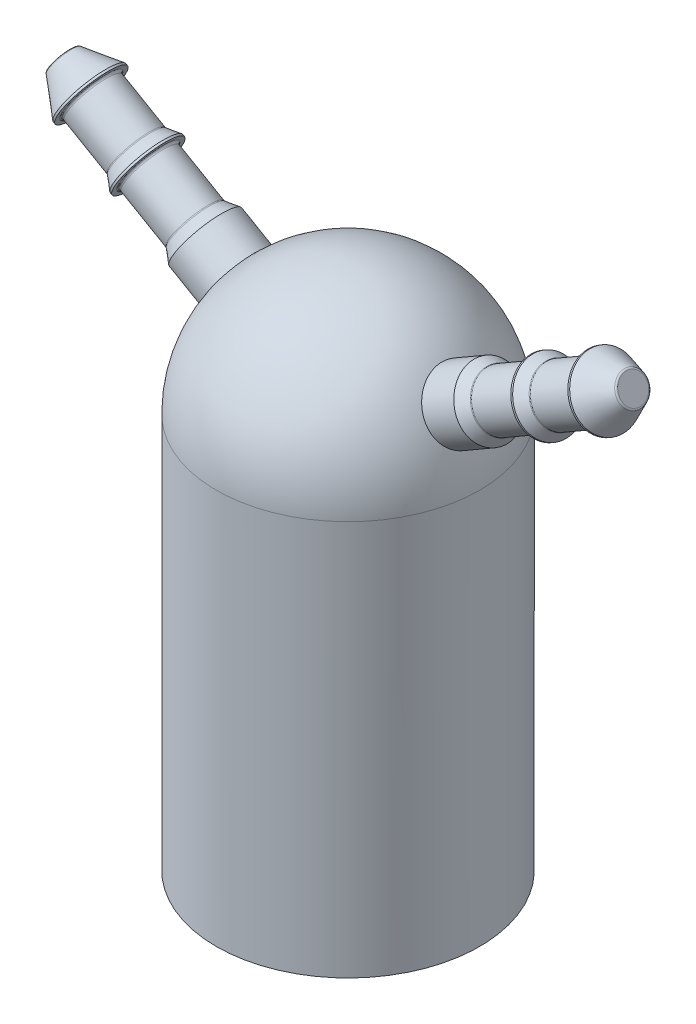
from build123d import *

# Parameters (mm, degrees)
CUT_EXTRUDE1_DEPTH   = 12.7
FILLET1_R            = 0.1016
FILLET1_OF_MIRROR1_R = 0.1016


with BuildPart() as part:
    # Sketch1 → Revolve1 (revolve)
    with BuildSketch(Plane.XY):
        with BuildLine():
            Line((0, 0), (0, 25.4))
            ThreePointArc((0, 25.4), (-4.490128061, 23.540128061), (-6.35, 19.05))
            Line((-6.35, 19.05), (-6.35, 0))
            Line((-6.35, 0), (0, 0))
        make_face()
    revolve(axis=Axis((0, 0, 0), (0, 1, 0)))

    # Sketch2 → Cut-Extrude1 (cut)
    with BuildSketch(Plane.XZ):
        with BuildLine():
            Line((2.87588847, 3.052663666), (2.491556541, 2.644707609))
            ThreePointArc((2.491556541, 2.644707609), (2.422052451, 2.612873916), (2.350030514, 2.638506769))
            ThreePointArc((2.350030514, 2.638506769), (2.10893298, 2.83491853), (1.851499358, 3.009370618))
            ThreePointArc((1.851499358, 3.009370618), (1.80624286, 3.070982727), (1.816750694, 3.146704507))
            Line((1.816750694, 3.146704507), (2.096991294, 3.632095464))
            add(Edge.make_bspline(
                [(2.133429555, 4.749876804), (2.173353678, 4.56476612), (2.196583124, 4.376018446), (2.195632116, 4.092198703), (2.189337304, 3.997490868), (2.16733456, 3.857272905), (2.157906341, 3.810840598), (2.133266211, 3.719484674), (2.11977921, 3.673567613), (2.096991294, 3.632095464)],
                knots=[0, 0, 0, 0, 0.5, 0.5, 0.75, 0.75, 0.875, 0.875, 1, 1, 1, 1], degree=3))
            ThreePointArc((2.133429555, 4.749876804), (1.920714415, 4.839804486), (1.704220965, 4.920211604))
            add(Edge.make_bspline(
                [(0.964260641, 4.081628519), (0.976112248, 4.127440828), (0.997781643, 4.170110641), (1.042491275, 4.253501826), (1.11742258, 4.374285652), (1.207964167, 4.484162484), (1.401892207, 4.691397776), (1.548227803, 4.812852233), (1.704220965, 4.920211604)],
                knots=[0, 0, 0, 0, 0.125, 0.125, 0.25, 0.5, 0.5, 1, 1, 1, 1], degree=3))
            Line((0.964260641, 4.081628519), (0.835397453, 3.536162244))
            ThreePointArc((0.835397453, 3.536162244), (0.791121992, 3.473841414), (0.71593274, 3.460029147))
            ThreePointArc((0.71593274, 3.460029147), (0.408930271, 3.509577955), (0.09876017, 3.531941083))
            ThreePointArc((0.09876017, 3.531941083), (0.028760839, 3.562670485), (0, 3.633501387))
            Line((0, 3.633501387), (0, 4.193982588))
            add(Edge.make_bspline(
                [(-0.527334211, 5.180228755), (-0.400203563, 5.039880261), (-0.285712436, 4.888034703), (-0.144626161, 4.641764092), (-0.102723711, 4.556597294), (-0.051669665, 4.424163605), (-0.036618589, 4.379237938), (-0.012279605, 4.287801322), (-0.00100116, 4.24129248), (0, 4.193982588)],
                knots=[0, 0, 0, 0, 0.5, 0.5, 0.75, 0.75, 0.875, 0.875, 1, 1, 1, 1], degree=3))
            ThreePointArc((-0.527334211, 5.180228755), (-0.756514766, 5.151750841), (-0.984207153, 5.113138723))
            add(Edge.make_bspline(
                [(-1.205740048, 4.016924306), (-1.21838241, 4.062524733), (-1.22095107, 4.110312573), (-1.223926985, 4.204886274), (-1.219426485, 4.346953788), (-1.195953586, 4.487380709), (-1.131624624, 4.763815757), (-1.065621508, 4.942166199), (-0.984207153, 5.113138723)],
                knots=[0, 0, 0, 0, 0.125, 0.125, 0.25, 0.5, 0.5, 1, 1, 1, 1], degree=3))
            Line((-1.205740048, 4.016924306), (-1.044605706, 3.480105064))
            ThreePointArc((-1.044605706, 3.480105064), (-1.051788963, 3.40399591), (-1.109998633, 3.354439509))
            ThreePointArc((-1.109998633, 3.354439509), (-1.400644974, 3.243848801), (-1.680441725, 3.108130788))
            ThreePointArc((-1.680441725, 3.108130788), (-1.756427626, 3.099743565), (-1.816750695, 3.146704507))
            Line((-1.816750695, 3.146704507), (-2.096991295, 3.632095464))
            add(Edge.make_bspline(
                [(-3.046799201, 4.222542594), (-2.866526584, 4.164562557), (-2.69145158, 4.090306009), (-2.446131977, 3.947572541), (-2.367259991, 3.894767156), (-2.256829045, 3.80560324), (-2.221331598, 3.774222009), (-2.154535111, 3.707205069), (-2.121513271, 3.672566452), (-2.096991295, 3.632095464)],
                knots=[0, 0, 0, 0, 0.5, 0.5, 0.75, 0.75, 0.875, 0.875, 1, 1, 1, 1], degree=3))
            ThreePointArc((-3.046799201, 4.222542594), (-3.231036427, 4.083289719), (-3.408917759, 3.936004451))
            add(Edge.make_bspline(
                [(-3.052663666, 2.87588847), (-3.086412486, 2.909058417), (-3.112530931, 2.949159571), (-3.162394999, 3.029574841), (-3.229531209, 3.154859167), (-3.279416543, 3.288208898), (-3.361923551, 3.559773153), (-3.393938397, 3.747230725), (-3.408917759, 3.936004451)],
                knots=[0, 0, 0, 0, 0.125, 0.125, 0.25, 0.5, 0.5, 1, 1, 1, 1], degree=3))
            Line((-3.052663666, 2.87588847), (-2.644707609, 2.491556541))
            ThreePointArc((-2.644707609, 2.491556541), (-2.612873915, 2.422052451), (-2.638506768, 2.350030514))
            ThreePointArc((-2.638506768, 2.350030514), (-2.834918529, 2.10893298), (-3.009370617, 1.851499357))
            ThreePointArc((-3.009370617, 1.851499357), (-3.070982726, 1.80624286), (-3.146704505, 1.816750694))
            Line((-3.146704505, 1.816750694), (-3.632095463, 2.096991294))
            add(Edge.make_bspline(
                [(-4.749876803, 2.133429555), (-4.564766119, 2.173353678), (-4.376018444, 2.196583123), (-4.092198702, 2.195632116), (-3.997490866, 2.189337304), (-3.857272903, 2.16733456), (-3.810840597, 2.157906341), (-3.719484672, 2.133266211), (-3.673567612, 2.11977921), (-3.632095463, 2.096991294)],
                knots=[0, 0, 0, 0, 0.5, 0.5, 0.75, 0.75, 0.875, 0.875, 1, 1, 1, 1], degree=3))
            ThreePointArc((-4.749876803, 2.133429555), (-4.839804484, 1.920714414), (-4.920211602, 1.704220964))
            add(Edge.make_bspline(
                [(-4.081628517, 0.96426064), (-4.127440826, 0.976112247), (-4.17011064, 0.997781642), (-4.253501824, 1.042491275), (-4.374285651, 1.117422579), (-4.484162483, 1.207964167), (-4.691397775, 1.401892206), (-4.812852231, 1.548227802), (-4.920211602, 1.704220964)],
                knots=[0, 0, 0, 0, 0.125, 0.125, 0.25, 0.5, 0.5, 1, 1, 1, 1], degree=3))
            Line((-4.081628517, 0.96426064), (-3.536162243, 0.835397452))
            ThreePointArc((-3.536162243, 0.835397452), (-3.473841412, 0.791121992), (-3.460029146, 0.71593274))
            ThreePointArc((-3.460029146, 0.71593274), (-3.509577953, 0.40893027), (-3.531941082, 0.09876017))
            ThreePointArc((-3.531941082, 0.09876017), (-3.562670484, 0.028760839), (-3.633501385, 0))
            Line((-3.633501385, 0), (-4.193982587, 0))
            add(Edge.make_bspline(
                [(-5.180228753, -0.527334211), (-5.03988026, -0.400203563), (-4.888034702, -0.285712437), (-4.641764091, -0.144626162), (-4.556597293, -0.102723711), (-4.424163603, -0.051669665), (-4.379237937, -0.036618589), (-4.287801321, -0.012279605), (-4.241292479, -0.00100116), (-4.193982587, 0)],
                knots=[0, 0, 0, 0, 0.5, 0.5, 0.75, 0.75, 0.875, 0.875, 1, 1, 1, 1], degree=3))
            ThreePointArc((-5.180228753, -0.527334211), (-5.15175084, -0.756514766), (-5.113138722, -0.984207153))
            add(Edge.make_bspline(
                [(-4.016924305, -1.205740048), (-4.062524732, -1.21838241), (-4.110312572, -1.22095107), (-4.204886272, -1.223926985), (-4.346953787, -1.219426485), (-4.487380708, -1.195953586), (-4.763815755, -1.131624624), (-4.942166198, -1.065621508), (-5.113138722, -0.984207153)],
                knots=[0, 0, 0, 0, 0.125, 0.125, 0.25, 0.5, 0.5, 1, 1, 1, 1], degree=3))
            Line((-4.016924305, -1.205740048), (-3.480105063, -1.044605706))
            ThreePointArc((-3.480105063, -1.044605706), (-3.403995909, -1.051788963), (-3.354439508, -1.109998633))
            ThreePointArc((-3.354439508, -1.109998633), (-3.2438488, -1.400644974), (-3.108130787, -1.680441724))
            ThreePointArc((-3.108130787, -1.680441724), (-3.099743564, -1.756427625), (-3.146704506, -1.816750694))
            Line((-3.146704506, -1.816750694), (-3.632095463, -2.096991294))
            add(Edge.make_bspline(
                [(-4.222542593, -3.0467992), (-4.164562556, -2.866526583), (-4.090306008, -2.69145158), (-3.94757254, -2.446131976), (-3.894767155, -2.367259991), (-3.805603238, -2.256829045), (-3.774222008, -2.221331597), (-3.707205068, -2.154535111), (-3.672566451, -2.12151327), (-3.632095463, -2.096991294)],
                knots=[0, 0, 0, 0, 0.5, 0.5, 0.75, 0.75, 0.875, 0.875, 1, 1, 1, 1], degree=3))
            ThreePointArc((-4.222542593, -3.0467992), (-4.083289718, -3.231036426), (-3.93600445, -3.408917758))
            add(Edge.make_bspline(
                [(-2.875888469, -3.052663665), (-2.909058416, -3.086412485), (-2.94915957, -3.11253093), (-3.02957484, -3.162394998), (-3.154859166, -3.229531208), (-3.288208897, -3.279416542), (-3.559773152, -3.36192355), (-3.747230724, -3.393938396), (-3.93600445, -3.408917758)],
                knots=[0, 0, 0, 0, 0.125, 0.125, 0.25, 0.5, 0.5, 1, 1, 1, 1], degree=3))
            Line((-2.875888469, -3.052663665), (-2.49155654, -2.644707608))
            ThreePointArc((-2.49155654, -2.644707608), (-2.42205245, -2.612873915), (-2.350030513, -2.638506767))
            ThreePointArc((-2.350030513, -2.638506767), (-2.108932979, -2.834918528), (-1.851499357, -3.009370616))
            ThreePointArc((-1.851499357, -3.009370616), (-1.806242859, -3.070982725), (-1.816750693, -3.146704504))
            Line((-1.816750693, -3.146704504), (-2.096991293, -3.632095462))
            add(Edge.make_bspline(
                [(-2.133429554, -4.749876802), (-2.173353677, -4.564766118), (-2.196583122, -4.376018443), (-2.195632115, -4.092198701), (-2.189337303, -3.997490865), (-2.167334559, -3.857272902), (-2.15790634, -3.810840596), (-2.13326621, -3.719484671), (-2.119779209, -3.673567611), (-2.096991293, -3.632095462)],
                knots=[0, 0, 0, 0, 0.5, 0.5, 0.75, 0.75, 0.875, 0.875, 1, 1, 1, 1], degree=3))
            ThreePointArc((-2.133429554, -4.749876802), (-1.920714414, -4.839804483), (-1.704220964, -4.920211601))
            add(Edge.make_bspline(
                [(-0.96426064, -4.081628516), (-0.976112247, -4.127440825), (-0.997781642, -4.170110639), (-1.042491274, -4.253501823), (-1.117422579, -4.37428565), (-1.207964166, -4.484162482), (-1.401892206, -4.691397774), (-1.548227802, -4.81285223), (-1.704220964, -4.920211601)],
                knots=[0, 0, 0, 0, 0.125, 0.125, 0.25, 0.5, 0.5, 1, 1, 1, 1], degree=3))
            Line((-0.96426064, -4.081628516), (-0.835397452, -3.536162242))
            ThreePointArc((-0.835397452, -3.536162242), (-0.791121991, -3.473841411), (-0.715932739, -3.460029145))
            ThreePointArc((-0.715932739, -3.460029145), (-0.40893027, -3.509577952), (-0.09876017, -3.531941081))
            ThreePointArc((-0.09876017, -3.531941081), (-0.028760839, -3.562670483), (0, -3.633501384))
            Line((0, -3.633501384), (0, -4.193982585))
            add(Edge.make_bspline(
                [(0.527334211, -5.180228752), (0.400203563, -5.039880259), (0.285712437, -4.8880347), (0.144626162, -4.64176409), (0.102723711, -4.556597292), (0.051669665, -4.424163602), (0.036618589, -4.379237936), (0.012279605, -4.28780132), (0.00100116, -4.241292478), (0, -4.193982585)],
                knots=[0, 0, 0, 0, 0.5, 0.5, 0.75, 0.75, 0.875, 0.875, 1, 1, 1, 1], degree=3))
            ThreePointArc((0.527334211, -5.180228752), (0.756514766, -5.151750839), (0.984207152, -5.113138721))
            add(Edge.make_bspline(
                [(1.205740048, -4.016924304), (1.21838241, -4.062524731), (1.22095107, -4.110312571), (1.223926985, -4.204886271), (1.219426485, -4.346953786), (1.195953586, -4.487380707), (1.131624624, -4.763815754), (1.065621508, -4.942166197), (0.984207152, -5.113138721)],
                knots=[0, 0, 0, 0, 0.125, 0.125, 0.25, 0.5, 0.5, 1, 1, 1, 1], degree=3))
            Line((1.205740048, -4.016924304), (1.044605706, -3.480105061))
            ThreePointArc((1.044605706, -3.480105061), (1.051788964, -3.403995909), (1.109998633, -3.354439509))
            ThreePointArc((1.109998633, -3.354439509), (1.400644974, -3.243848801), (1.680441725, -3.108130788))
            ThreePointArc((1.680441725, -3.108130788), (1.756427626, -3.099743566), (1.816750694, -3.146704507))
            Line((1.816750694, -3.146704507), (2.096991294, -3.632095464))
            add(Edge.make_bspline(
                [(3.0467992, -4.222542594), (2.866526583, -4.164562557), (2.69145158, -4.090306009), (2.446131976, -3.947572542), (2.367259991, -3.894767157), (2.256829045, -3.80560324), (2.221331597, -3.77422201), (2.154535111, -3.707205069), (2.121513271, -3.672566453), (2.096991294, -3.632095464)],
                knots=[0, 0, 0, 0, 0.5, 0.5, 0.75, 0.75, 0.875, 0.875, 1, 1, 1, 1], degree=3))
            ThreePointArc((3.0467992, -4.222542594), (3.231036427, -4.08328972), (3.408917759, -3.936004451))
            add(Edge.make_bspline(
                [(3.052663666, -2.87588847), (3.086412486, -2.909058417), (3.112530931, -2.949159571), (3.162394999, -3.029574841), (3.229531209, -3.154859167), (3.279416543, -3.288208898), (3.361923551, -3.559773153), (3.393938397, -3.747230725), (3.408917759, -3.936004451)],
                knots=[0, 0, 0, 0, 0.125, 0.125, 0.25, 0.5, 0.5, 1, 1, 1, 1], degree=3))
            Line((3.052663666, -2.87588847), (2.644707609, -2.491556541))
            ThreePointArc((2.644707609, -2.491556541), (2.612873916, -2.422052451), (2.638506769, -2.350030514))
            ThreePointArc((2.638506769, -2.350030514), (2.834918531, -2.10893298), (3.009370618, -1.851499358))
            ThreePointArc((3.009370618, -1.851499358), (3.070982727, -1.80624286), (3.146704507, -1.816750694))
            Line((3.146704507, -1.816750694), (3.632095464, -2.096991294))
            add(Edge.make_bspline(
                [(4.749876805, -2.133429555), (4.56476612, -2.173353678), (4.376018446, -2.196583124), (4.092198703, -2.195632116), (3.997490868, -2.189337304), (3.857272905, -2.16733456), (3.810840598, -2.157906341), (3.719484674, -2.133266211), (3.673567613, -2.11977921), (3.632095464, -2.096991294)],
                knots=[0, 0, 0, 0, 0.5, 0.5, 0.75, 0.75, 0.875, 0.875, 1, 1, 1, 1], degree=3))
            ThreePointArc((4.749876805, -2.133429555), (4.839804486, -1.920714415), (4.920211604, -1.704220965))
            add(Edge.make_bspline(
                [(4.081628519, -0.964260641), (4.127440828, -0.976112248), (4.170110641, -0.997781643), (4.253501826, -1.042491275), (4.374285653, -1.11742258), (4.484162484, -1.207964167), (4.691397777, -1.401892207), (4.812852233, -1.548227803), (4.920211604, -1.704220965)],
                knots=[0, 0, 0, 0, 0.125, 0.125, 0.25, 0.5, 0.5, 1, 1, 1, 1], degree=3))
            Line((4.081628519, -0.964260641), (3.536162244, -0.835397453))
            ThreePointArc((3.536162244, -0.835397453), (3.473841414, -0.791121992), (3.460029147, -0.71593274))
            ThreePointArc((3.460029147, -0.71593274), (3.509577955, -0.408930271), (3.531941083, -0.09876017))
            ThreePointArc((3.531941083, -0.09876017), (3.562670486, -0.028760839), (3.633501387, 0))
            Line((3.633501387, 0), (4.193982588, 0))
            add(Edge.make_bspline(
                [(5.180228755, 0.52733421), (5.039880262, 0.400203563), (4.888034703, 0.285712436), (4.641764092, 0.144626161), (4.556597295, 0.102723711), (4.424163605, 0.051669665), (4.379237938, 0.036618589), (4.287801322, 0.012279605), (4.24129248, 0.00100116), (4.193982588, 0)],
                knots=[0, 0, 0, 0, 0.5, 0.5, 0.75, 0.75, 0.875, 0.875, 1, 1, 1, 1], degree=3))
            ThreePointArc((5.180228755, 0.52733421), (5.151750842, 0.756514766), (5.113138723, 0.984207153))
            add(Edge.make_bspline(
                [(4.016924307, 1.205740048), (4.062524733, 1.218382411), (4.110312573, 1.22095107), (4.204886274, 1.223926985), (4.346953788, 1.219426485), (4.48738071, 1.195953586), (4.763815757, 1.131624624), (4.9421662, 1.065621508), (5.113138723, 0.984207153)],
                knots=[0, 0, 0, 0, 0.125, 0.125, 0.25, 0.5, 0.5, 1, 1, 1, 1], degree=3))
            Line((4.016924307, 1.205740048), (3.480105064, 1.044605706))
            ThreePointArc((3.480105064, 1.044605706), (3.40399591, 1.051788963), (3.354439509, 1.109998633))
            ThreePointArc((3.354439509, 1.109998633), (3.243848801, 1.400644974), (3.108130788, 1.680441724))
            ThreePointArc((3.108130788, 1.680441724), (3.099743565, 1.756427625), (3.146704507, 1.816750694))
            Line((3.146704507, 1.816750694), (3.632095464, 2.096991294))
            add(Edge.make_bspline(
                [(4.222542594, 3.0467992), (4.164562557, 2.866526583), (4.090306009, 2.69145158), (3.947572542, 2.446131976), (3.894767156, 2.367259991), (3.80560324, 2.256829045), (3.77422201, 2.221331597), (3.707205069, 2.154535111), (3.672566453, 2.12151327), (3.632095464, 2.096991294)],
                knots=[0, 0, 0, 0, 0.5, 0.5, 0.75, 0.75, 0.875, 0.875, 1, 1, 1, 1], degree=3))
            ThreePointArc((4.222542594, 3.0467992), (4.08328972, 3.231036426), (3.936004451, 3.408917759))
            add(Edge.make_bspline(
                [(2.87588847, 3.052663666), (2.909058417, 3.086412486), (2.949159571, 3.11253093), (3.029574841, 3.162394999), (3.154859167, 3.229531209), (3.288208898, 3.279416542), (3.559773153, 3.36192355), (3.747230725, 3.393938397), (3.936004451, 3.408917759)],
                knots=[0, 0, 0, 0, 0.125, 0.125, 0.25, 0.5, 0.5, 1, 1, 1, 1], degree=3))
        make_face()
    extrude(amount=-CUT_EXTRUDE1_DEPTH, mode=Mode.SUBTRACT)

    # Sketch3 → Revolve2 (revolve)
    with BuildSketch(Plane.XY):
        Polygon((-13.748153285, 26.9875), (-14.112960903, 26.355634671), (-13.255076138, 24.869734671), (-13.167087957, 24.818934671), (-13.008337957, 25.093897737), (-10.822945481, 23.832160803), (-10.505445481, 23.282234671), (-10.4174573, 23.231434671), (-10.2587073, 23.506397737), (-7.985326643, 22.193860803), (-7.667826643, 21.643934671), (-0.79375, 17.675184671), (0, 19.05), align=None)
    revolve2 = revolve(axis=Axis((0, 19.05, 0), (-0.866025404, 0.5, 0)))

    # Fillet1
    fillet1_edges = [part.edges().sort_by_distance(p)[0] for p in [
        (-6.715326643, 24.393565329, 0),
        (-8.9887073, 25.706102263, 0),
        (-9.552945481, 26.031865329, 0),
        (-11.738337957, 27.293602263, 0),
        (-13.383345668, 27.619365329, 0),
    ]]
    fillet(fillet1_edges, radius=FILLET1_R)

    # Mirror1: Revolve2 across plane
    add(revolve2.mirror(Plane(origin=(0, 0, 0), x_dir=(0, 0, 1), z_dir=(1, 0, 0))))

    # Fillet1 of Mirror1
    fillet1_of_mirror1_edges = [part.edges().sort_by_distance(p)[0] for p in [
        (6.715326643, 24.393565329, 0),
        (8.9887073, 25.706102263, 0),
        (9.552945481, 26.031865329, 0),
        (11.738337957, 27.293602263, 0),
        (13.383345668, 27.619365329, 0),
    ]]
    fillet(fillet1_of_mirror1_edges, radius=FILLET1_OF_MIRROR1_R)


solid = part.part
